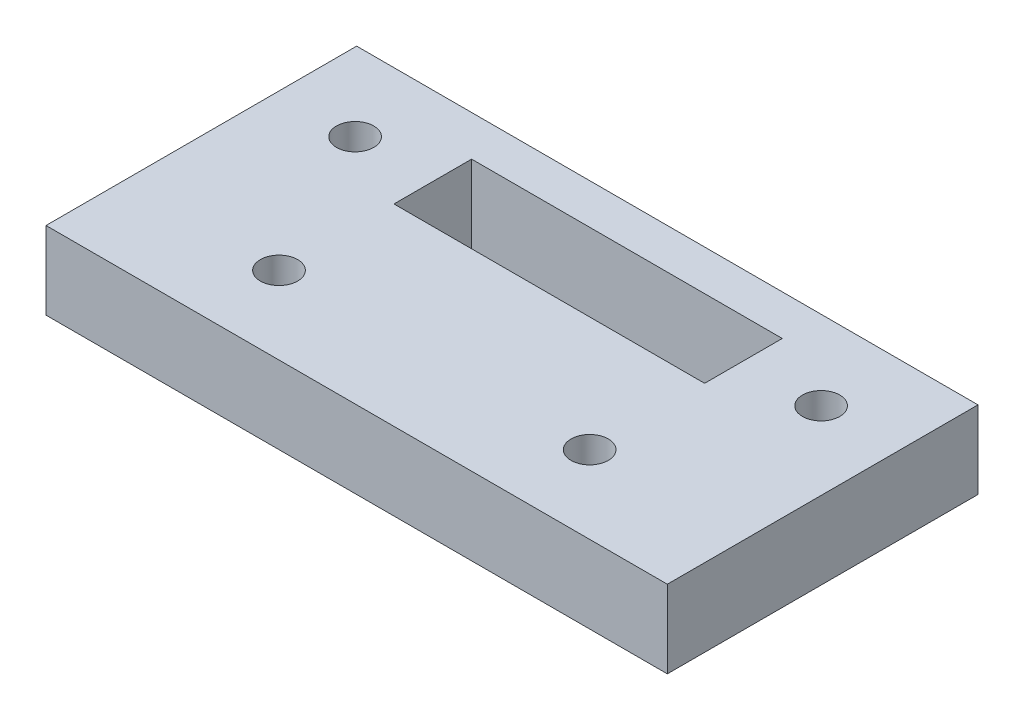
from build123d import *

# Parameters (mm, degrees)
SKETCH1_W           = 50.8
SKETCH1_H           = 25.4
SKETCH1_R           = 1.524
SKETCH1_W_2         = 25.4
SKETCH1_H_2         = 6.35
BOSS_EXTRUDE1_DEPTH = 6.35


with BuildPart() as part:
    # Sketch1 → Boss-Extrude1 (new body)
    with BuildSketch(Plane(origin=(0, 0, 0), x_dir=(1, 0, 0), z_dir=(0, 1, 0))):
        with Locations((25.4, -12.7)):
            Rectangle(SKETCH1_W, SKETCH1_H)
        with Locations((6.35, -6.477)):
            Circle(SKETCH1_R, mode=Mode.SUBTRACT)
        with Locations((44.45, -6.477)):
            Circle(SKETCH1_R, mode=Mode.SUBTRACT)
        with Locations((12.7, -19.05)):
            Circle(SKETCH1_R, mode=Mode.SUBTRACT)
        with Locations((38.1, -19.05)):
            Circle(SKETCH1_R, mode=Mode.SUBTRACT)
        with Locations((25.4, -6.477)):
            Rectangle(SKETCH1_W_2, SKETCH1_H_2, mode=Mode.SUBTRACT)
    extrude(amount=BOSS_EXTRUDE1_DEPTH)


solid = part.part
